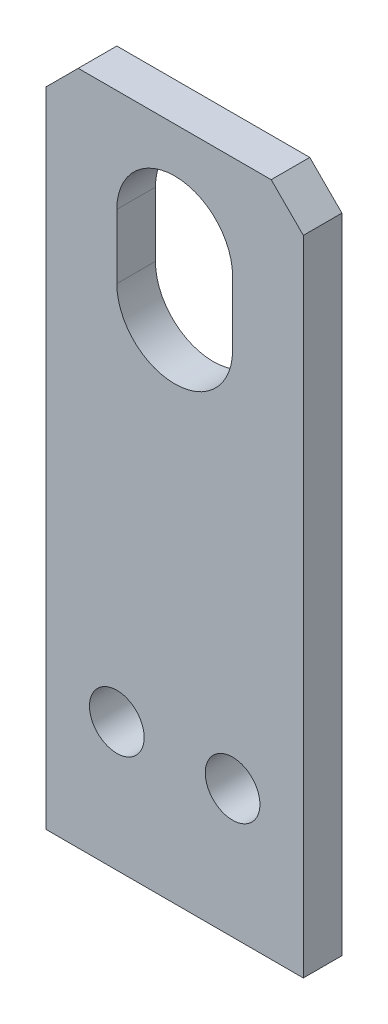
from build123d import *

# Parameters (mm, degrees)
SKETCH1_W           = 40
SKETCH1_H           = 105
SKETCH1_R           = 4.25
BOSS_EXTRUDE1_DEPTH = 3
CHAMFER1_SIZE       = 5


with BuildPart() as part:
    # Sketch1 → Boss-Extrude1 (new body, symmetric)
    with BuildSketch(Plane.XY):
        Rectangle(SKETCH1_W, SKETCH1_H)
        with Locations((9, -32.5)):
            Circle(SKETCH1_R, mode=Mode.SUBTRACT)
        with Locations((-9, -32.5)):
            Circle(SKETCH1_R, mode=Mode.SUBTRACT)
        with BuildLine():
            Line((9, 36.5), (9, 26.5))
            ThreePointArc((9, 26.5), (0, 17.5), (-9, 26.5))
            Line((-9, 26.5), (-9, 36.5))
            ThreePointArc((-9, 36.5), (0, 45.5), (9, 36.5))
        make_face(mode=Mode.SUBTRACT)
    extrude(amount=BOSS_EXTRUDE1_DEPTH, both=True)

    # Chamfer1
    chamfer1_edges = [part.edges().sort_by_distance(p)[0] for p in [
        (-20, 52.5, 0),
        (20, 52.5, 0),
    ]]
    chamfer(chamfer1_edges, length=CHAMFER1_SIZE)


solid = part.part
